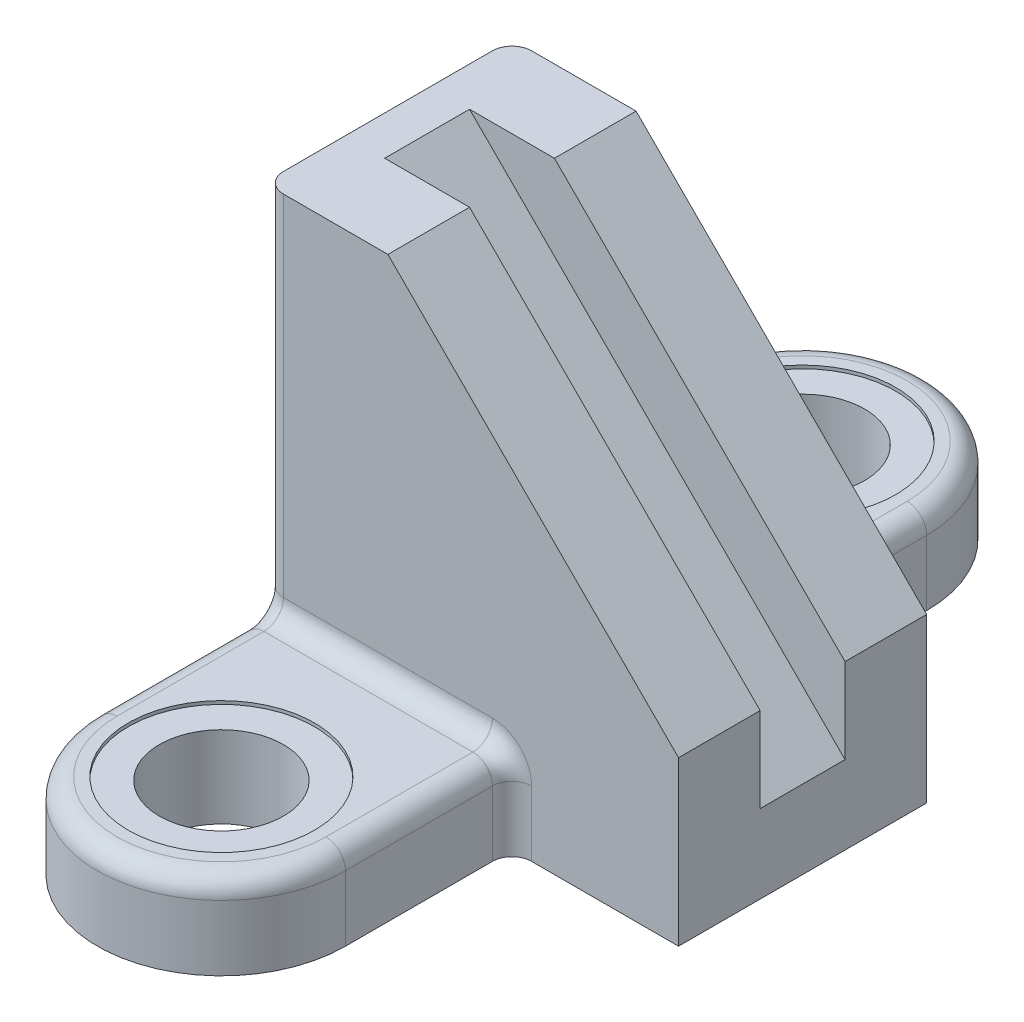
from build123d import *

# Parameters (mm, degrees)
BOSS_EXTRUDE1_DEPTH                      = 38
BOSS_EXTRUDE3_DEPTH                      = 26
FILLET1_R                                = 6
CBORE_FOR_M30_HEX_HEAD_BOLT2_D           = 38
CBORE_FOR_M30_HEX_HEAD_BOLT2_CBORE_D     = 57
CBORE_FOR_M30_HEX_HEAD_BOLT2_CBORE_DEPTH = 1
SKETCH17_W                               = 26
SKETCH17_H                               = 18.384776311
CUT_EXTRUDE3_DEPTH                       = 180.605122421


with BuildPart() as part:
    # Sketch1 → Boss-Extrude1 (new body, symmetric)
    with BuildSketch(Plane.XY):
        Polygon((38, 139), (127, 50), (127, 0), (0, 0), (0, 139), align=None)
    extrude(amount=BOSS_EXTRUDE1_DEPTH, both=True)

    # Sketch3 → Boss-Extrude3 (add)
    with BuildSketch(Plane(origin=(0, 0, 0), x_dir=(1, 0, 0), z_dir=(0, 1, 0))):
        with BuildLine():
            Line((0, 38), (76, 38))
            Line((76, 38), (76, 89))
            ThreePointArc((76, 89), (38, 127), (0, 89))
            Line((0, 89), (0, 38))
        make_face()
        with BuildLine():
            Line((0, -38), (76, -38))
            Line((76, -38), (76, -89))
            ThreePointArc((76, -89), (38, -127), (0, -89))
            Line((0, -89), (0, -38))
        make_face()
    extrude(amount=BOSS_EXTRUDE3_DEPTH)

    # Fillet1
    fillet1_edges = [part.edges().sort_by_distance(p)[0] for p in [
        (76, 13, -38),
        (0, 26, -63.5),
        (38, 26, -38),
        (76, 26, -63.5),
        (38, 26, -127),
        (76, 13, 38),
        (0, 26, 63.5),
        (38, 26, 127),
        (76, 26, 63.5),
        (38, 26, 38),
        (0, 82.5, 38),
        (0, 82.5, -38),
    ]]
    fillet(fillet1_edges, radius=FILLET1_R)

    # CBORE for M30 Hex Head Bolt2 (through all)
    with Locations(Plane(origin=(0, 26, 0), x_dir=(1, 0, 0), z_dir=(0, 1, 0))):
        with Locations((38, -89), (38, 89)):
            CounterBoreHole(CBORE_FOR_M30_HEX_HEAD_BOLT2_D / 2, CBORE_FOR_M30_HEX_HEAD_BOLT2_CBORE_D / 2, CBORE_FOR_M30_HEX_HEAD_BOLT2_CBORE_DEPTH)

    # Sketch17 → Cut-Extrude3 (cut, through all)
    with BuildSketch(Plane(origin=(-63.5, 63.5, 0), x_dir=(0, 0, -1), z_dir=(-0.707106781, 0.707106781, 0))):
        with Locations((0, -115.965512115)):
            Rectangle(SKETCH17_W, SKETCH17_H)
    extrude(amount=-CUT_EXTRUDE3_DEPTH, mode=Mode.SUBTRACT)


solid = part.part
